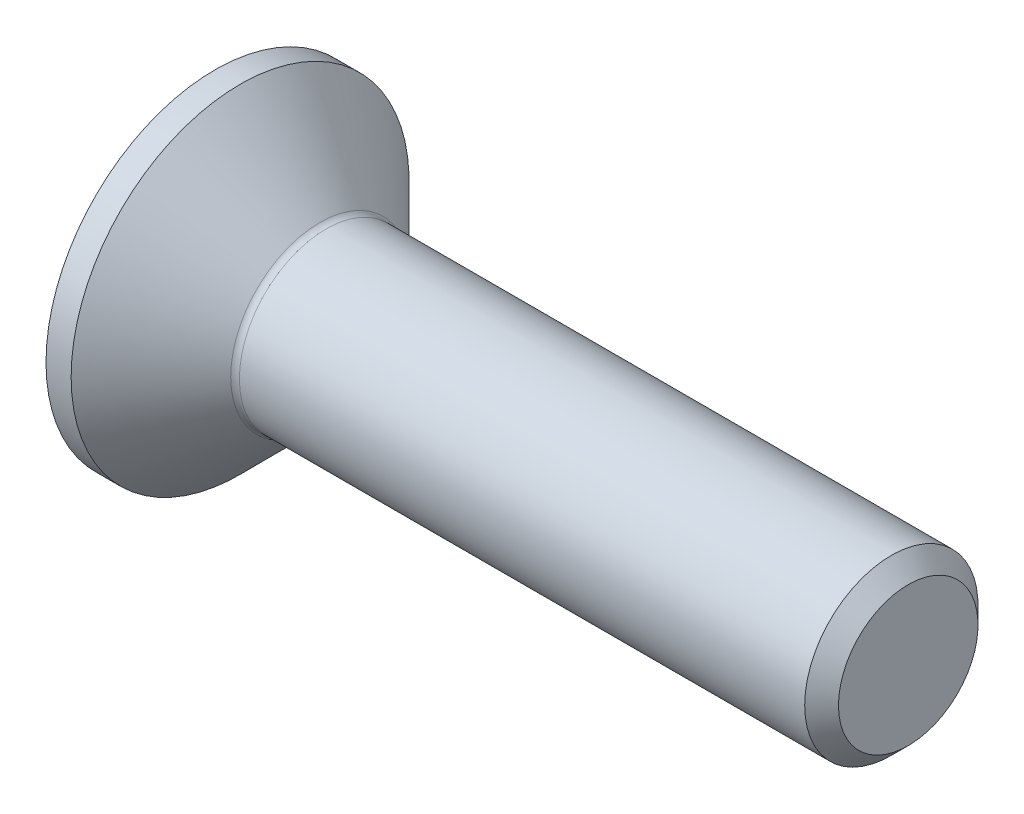
from build123d import *

# Parameters (mm, degrees)
FILLET1_R   = 0.2
HEX_2_DEPTH = 1.5


with BuildPart() as part:
    # BodySke → BaseBody (revolve)
    with BuildSketch(Plane.XY):
        Polygon((0, 0), (0, 3.9), (0.58, 3.9), (2.48, 2), (15.61, 2), (16, 1.61), (16, 0), align=None)
    revolve(axis=Axis((0, 0, 0), (1, 0, 0)))

    # Fillet1
    fillet1_edges = [part.edges().sort_by_distance(p)[0] for p in [
        (2.48, -2, 0),
    ]]
    fillet(fillet1_edges, radius=FILLET1_R)

    # Sketch2 → PreBroach (revolve, cut)
    with BuildSketch(Plane.XY):
        Polygon((0, 1.25), (1.5, 1.25), (2.221687836, 0), (0, 0), align=None)
    revolve(axis=Axis((0, 0, 0), (1, 0, 0)), mode=Mode.SUBTRACT)

    # Sketch3 → Hex 2 (cut)
    with BuildSketch(Plane.ZY):
        Polygon((-1.25, -0.721687836), (-1.25, 0.721687836), (0, 1.443375673), (1.25, 0.721687836), (1.25, -0.721687836), (0, -1.443375673), align=None)
    extrude(amount=-HEX_2_DEPTH, mode=Mode.SUBTRACT)


solid = part.part
